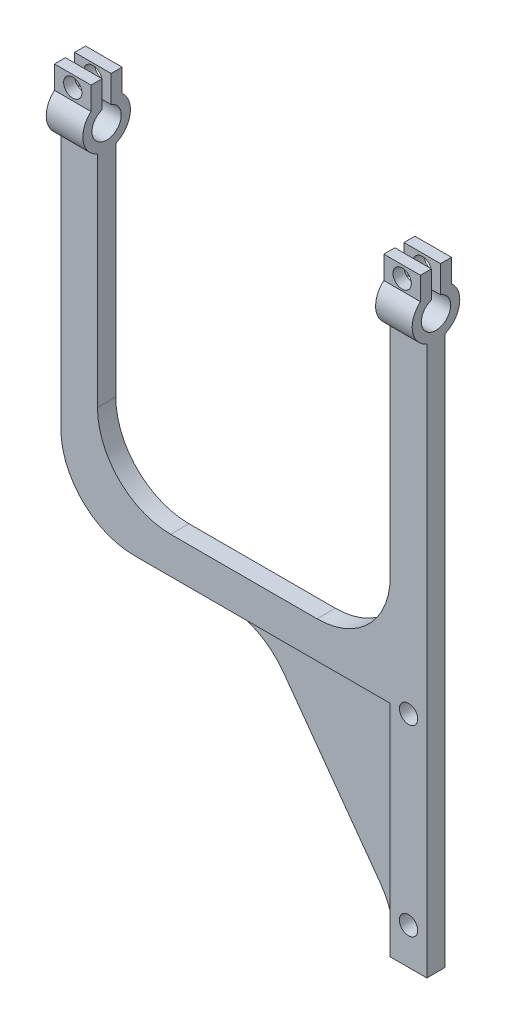
from build123d import *

# Parameters (mm, degrees)
SKETCH1_W           = 10
SKETCH1_H           = 70
SKETCH1_R           = 2.5
BOSS_EXTRUDE1_DEPTH = 5
SKETCH2_W           = 5
SKETCH2_H           = 10
BOSS_EXTRUDE2_DEPTH = 90
BOSS_EXTRUDE3_DEPTH = 4
SKETCH5_W           = 10
SKETCH5_H           = 5
BOSS_EXTRUDE4_DEPTH = 80
BOSS_EXTRUDE5_DEPTH = 10
SKETCH7_R           = 2.5
CUT_EXTRUDE1_DEPTH  = 10
BOSS_EXTRUDE6_DEPTH = 10
SKETCH9_R           = 2.5
CUT_EXTRUDE2_DEPTH  = 10
CUT_EXTRUDE3_DEPTH  = 1
FILLET1_R           = 20


with BuildPart() as part:
    # Sketch1 → Boss-Extrude1 (new body)
    with BuildSketch(Plane.XY):
        with Locations((-11.402877698, -2.158273381)):
            Rectangle(SKETCH1_W, SKETCH1_H)
        with Locations((-11.402877698, 22.841726619)):
            Circle(SKETCH1_R, mode=Mode.SUBTRACT)
        with Locations((-11.402877698, -27.158273381)):
            Circle(SKETCH1_R, mode=Mode.SUBTRACT)
    extrude(amount=BOSS_EXTRUDE1_DEPTH)

    # Sketch2 → Boss-Extrude2 (add)
    with BuildSketch(Plane.ZY.offset(16.402877698)):
        with Locations((2.5, 27.841726619)):
            Rectangle(SKETCH2_W, SKETCH2_H)
    extrude(amount=BOSS_EXTRUDE2_DEPTH)

    # Sketch3 → Boss-Extrude3 (add)
    with BuildSketch(Plane(origin=(0, 0, 0), x_dir=(-1, 0, 0), z_dir=(0, 0, -1))):
        Polygon((16.402877698, -27.158273381), (52.551297267, 22.841726619), (16.402877698, 22.841726619), align=None)
    extrude(amount=-BOSS_EXTRUDE3_DEPTH)

    # Sketch5 → Boss-Extrude4 (add)
    with BuildSketch(Plane(origin=(0, 32.841726619, 0), x_dir=(1, 0, 0), z_dir=(0, 1, 0))):
        with Locations((-11.402877698, -2.5)):
            Rectangle(SKETCH5_W, SKETCH5_H)
        with Locations((-101.402877698, -2.5)):
            Rectangle(SKETCH5_W, SKETCH5_H)
    extrude(amount=BOSS_EXTRUDE4_DEPTH)

    # Sketch6 → Boss-Extrude5 (add)
    with BuildSketch(Plane(origin=(-6.402877698, 0, 0), x_dir=(0, 0, -1), z_dir=(1, 0, 0))):
        with BuildLine():
            Line((-6.75, 130.009805512), (-6.75, 123.759805512))
            ThreePointArc((-6.75, 123.759805512), (-5.34531818, 124.685883055), (-3.75, 125.22040203))
            Line((-3.75, 125.22040203), (-3.75, 130.009805512))
            Line((-3.75, 130.009805512), (-6.75, 130.009805512))
        make_face()
        with BuildLine():
            ThreePointArc((-3.75, 125.22040203), (-5.34531818, 124.685883055), (-6.75, 123.759805512))
            ThreePointArc((-6.75, 123.759805512), (-8.918078893, 117.813007357), (-5, 112.841726619))
            Line((-5, 112.841726619), (0, 112.841726619))
            ThreePointArc((0, 112.841726619), (2.908326913, 115.236175343), (4, 118.841726619))
            ThreePointArc((4, 118.841726619), (3.410795209, 121.545890075), (1.75, 123.759805512))
            ThreePointArc((1.75, 123.759805512), (0.34531818, 124.685883055), (-1.25, 125.22040203))
            Line((-1.25, 125.22040203), (-1.25, 122.641397657))
            ThreePointArc((-1.25, 122.641397657), (0.740370349, 121.186934499), (1.5, 118.841726619))
            ThreePointArc((1.5, 118.841726619), (-4.84520788, 115.60135627), (-3.75, 122.641397657))
            Line((-3.75, 122.641397657), (-3.75, 125.22040203))
        make_face()
        with BuildLine():
            Line((-1.25, 130.009805512), (-1.25, 125.22040203))
            ThreePointArc((-1.25, 125.22040203), (0.34531818, 124.685883055), (1.75, 123.759805512))
            Line((1.75, 123.759805512), (1.75, 130.009805512))
            Line((1.75, 130.009805512), (-1.25, 130.009805512))
        make_face()
    extrude(amount=-BOSS_EXTRUDE5_DEPTH)

    # Sketch7 → Cut-Extrude1 (cut)
    with BuildSketch(Plane(origin=(0, 0, -1.75), x_dir=(-1, 0, 0), z_dir=(0, 0, -1))):
        with Locations((11.402877698, 126.736200343)):
            Circle(SKETCH7_R)
    extrude(amount=-CUT_EXTRUDE1_DEPTH, mode=Mode.SUBTRACT)

    # Sketch8 → Boss-Extrude6 (add)
    with BuildSketch(Plane.ZY.offset(106.402877698)):
        with BuildLine():
            ThreePointArc((1.25, 125.22040203), (-0.34531818, 124.685883055), (-1.75, 123.759805512))
            ThreePointArc((-1.75, 123.759805512), (-3.918078893, 117.813007357), (0, 112.841726619))
            Line((0, 112.841726619), (5, 112.841726619))
            ThreePointArc((5, 112.841726619), (7.908326913, 115.236175343), (9, 118.841726619))
            ThreePointArc((9, 118.841726619), (8.410795209, 121.545890075), (6.75, 123.759805512))
            ThreePointArc((6.75, 123.759805512), (5.34531818, 124.685883055), (3.75, 125.22040203))
            Line((3.75, 125.22040203), (3.75, 122.641397657))
            ThreePointArc((3.75, 122.641397657), (5.740370349, 121.186934499), (6.5, 118.841726619))
            ThreePointArc((6.5, 118.841726619), (0.15479212, 115.60135627), (1.25, 122.641397657))
            Line((1.25, 122.641397657), (1.25, 125.22040203))
        make_face()
        with BuildLine():
            Line((1.25, 130.009805512), (-1.75, 130.009805512))
            Line((-1.75, 130.009805512), (-1.75, 123.759805512))
            ThreePointArc((-1.75, 123.759805512), (-0.34531818, 124.685883055), (1.25, 125.22040203))
            Line((1.25, 125.22040203), (1.25, 130.009805512))
        make_face()
        with BuildLine():
            Line((3.75, 130.009805512), (3.75, 125.22040203))
            ThreePointArc((3.75, 125.22040203), (5.34531818, 124.685883055), (6.75, 123.759805512))
            Line((6.75, 123.759805512), (6.75, 130.009805512))
            Line((6.75, 130.009805512), (3.75, 130.009805512))
        make_face()
    extrude(amount=-BOSS_EXTRUDE6_DEPTH)

    # Sketch9 → Cut-Extrude2 (cut)
    with BuildSketch(Plane.XY.offset(6.75)):
        with Locations((-101.402877698, 126.921763381)):
            Circle(SKETCH9_R)
    extrude(amount=-CUT_EXTRUDE2_DEPTH, mode=Mode.SUBTRACT)

    # Sketch10 → Cut-Extrude3 (cut)
    with BuildSketch(Plane(origin=(0, 0, 0), x_dir=(-1, 0, 0), z_dir=(0, 0, -1))):
        Polygon((16.402877698, -27.158273381), (52.551297267, 22.841726619), (16.402877698, 22.841726619), align=None)
    extrude(amount=-CUT_EXTRUDE3_DEPTH, mode=Mode.SUBTRACT)

    # Fillet1
    fillet1_edges = [part.edges().sort_by_distance(p)[0] for p in [
        (-106.402877698, 22.841726619, 2.5),
        (-16.402877698, -27.158273381, 2.5),
        (-52.551297267, 22.841726619, 2.5),
        (-96.402877698, 32.841726619, 2.5),
        (-16.402877698, 32.841726619, 2.5),
    ]]
    fillet(fillet1_edges, radius=FILLET1_R)


solid = part.part
